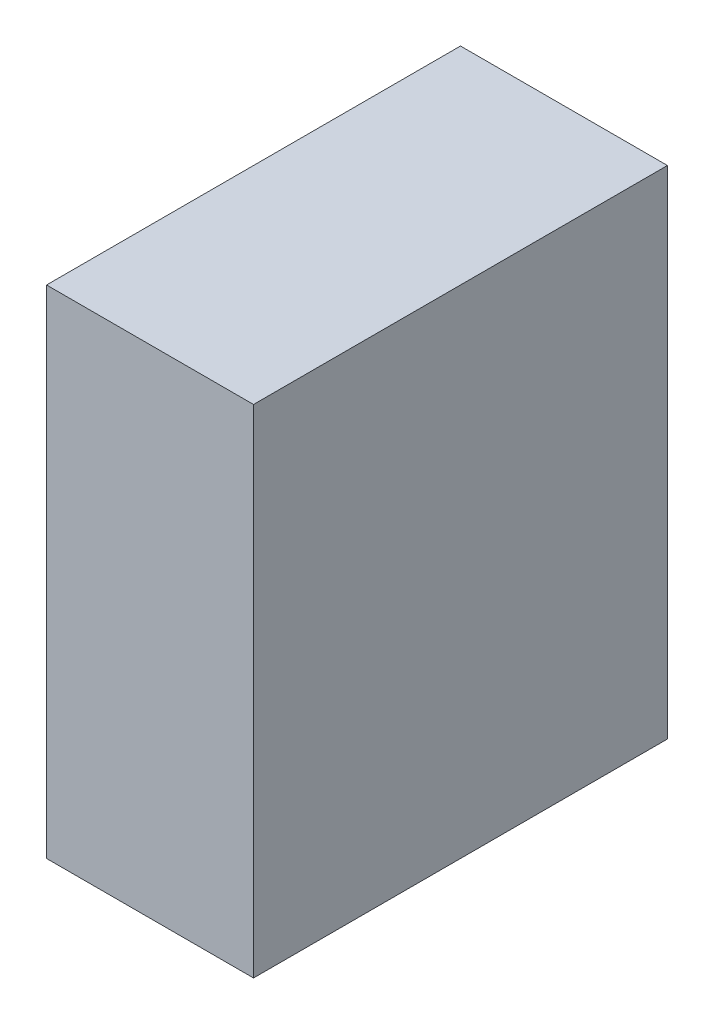
from build123d import *

# Parameters (mm, degrees)
SKETCH1_W           = 6.35
SKETCH1_H           = 7.62
BOSS_EXTRUDE1_DEPTH = 3.175


with BuildPart() as part:
    # Sketch1 → Boss-Extrude1 (new body)
    with BuildSketch(Plane(origin=(0, 0, 0), x_dir=(0, 0, -1), z_dir=(1, 0, 0))):
        with Locations((-6.879166667, 0.599722222)):
            Rectangle(SKETCH1_W, SKETCH1_H)
    extrude(amount=BOSS_EXTRUDE1_DEPTH)


solid = part.part
